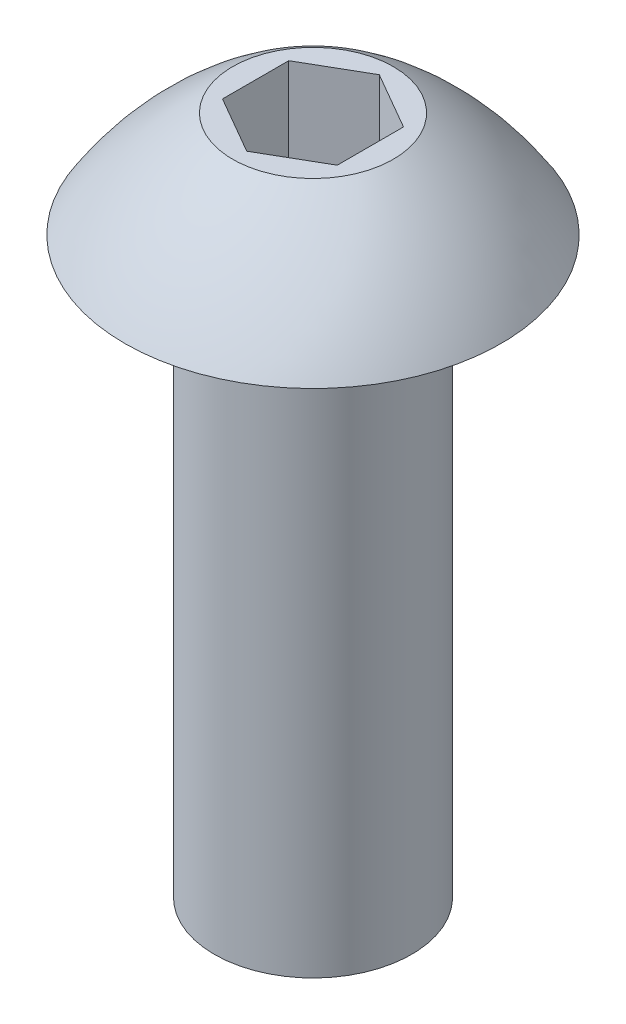
from build123d import *

# Parameters (mm, degrees)
CUT_EXTRUDE1_DEPTH = 1.27


with BuildPart() as part:
    # Sketch1 → Revolve1 (revolve)
    with BuildSketch(Plane.XY):
        with BuildLine():
            Line((-1.0922, 0), (-2.0828, 0))
            ThreePointArc((-2.0828, 0), (-1.555373888, 0.65518419), (-0.889, 1.1684))
            Line((-0.889, 1.1684), (0, 1.1684))
            Line((0, 1.1684), (0, -6.35))
            Line((0, -6.35), (-1.0922, -6.35))
            Line((-1.0922, -6.35), (-1.0922, 0))
        make_face()
    revolve(axis=Axis((0, -6.35, 0), (0, 1, 0)))

    # Sketch2 → Cut-Extrude1 (cut)
    with BuildSketch(Plane(origin=(0, 1.1684, 0), x_dir=(1, 0, 0), z_dir=(0, 1, 0))):
        Polygon((-0.635, 0.366617421), (-0.635, -0.366617421), (0, -0.733234842), (0.635, -0.366617421), (0.635, 0.366617421), (0, 0.733234842), align=None)
    extrude(amount=-CUT_EXTRUDE1_DEPTH, mode=Mode.SUBTRACT)


solid = part.part
